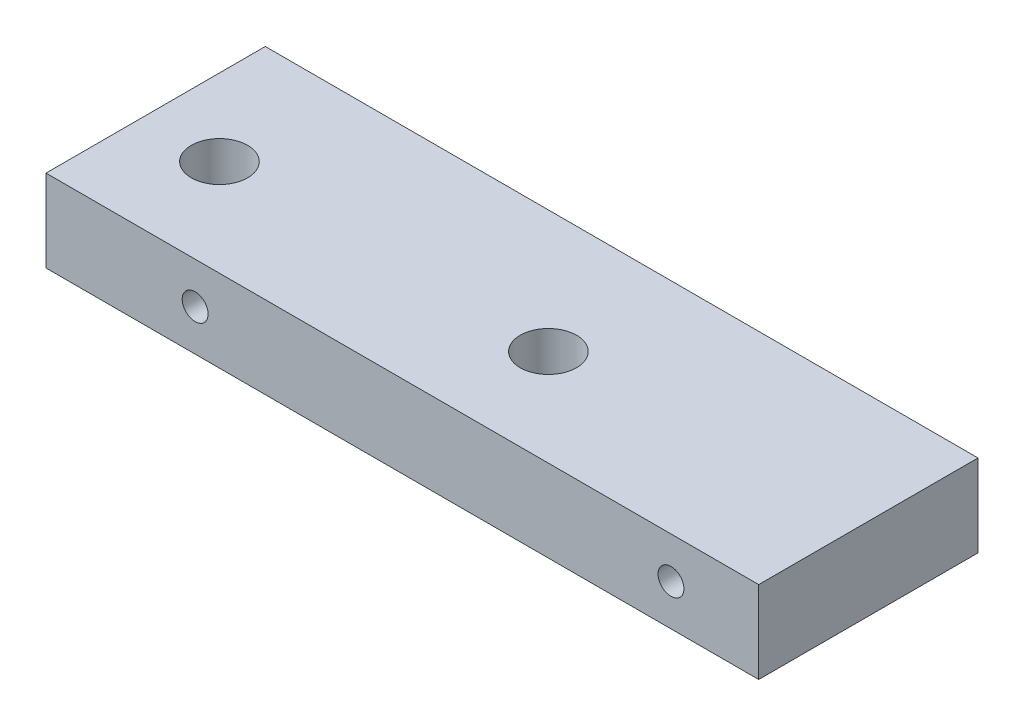
from build123d import *

# Parameters (mm, degrees)
SKETCH1_W               = 82.55
SKETCH1_H               = 25.4
BOSS_EXTRUDE1_DEPTH     = 9.525
F_1_4_CLEARANCE_HOLE1_D = 6.5278
SKETCH15_R              = 1.5
CUT_EXTRUDE1_DEPTH      = 26.4


with BuildPart() as part:
    # Sketch1 → Boss-Extrude1 (new body)
    with BuildSketch(Plane(origin=(0, 0, 0), x_dir=(1, 0, 0), z_dir=(0, 1, 0))):
        with Locations((-41.275, -12.7)):
            Rectangle(SKETCH1_W, SKETCH1_H)
    extrude(amount=BOSS_EXTRUDE1_DEPTH)

    # 1/4 Clearance Hole1 (through all)
    with Locations(Plane(origin=(0, 9.525, 0), x_dir=(1, 0, 0), z_dir=(0, 1, 0))):
        with Locations((-73.66, -14.200000048), (-35.56, -14.200000048)):
            Hole(F_1_4_CLEARANCE_HOLE1_D / 2)

    # Sketch15 → Cut-Extrude1 (cut, through all)
    with BuildSketch(Plane.XY.offset(25.4)):
        with Locations((-65.278, 4.7625)):
            Circle(SKETCH15_R)
        with Locations((-10.16, 4.7625)):
            Circle(SKETCH15_R)
    extrude(amount=-CUT_EXTRUDE1_DEPTH, mode=Mode.SUBTRACT)


solid = part.part
